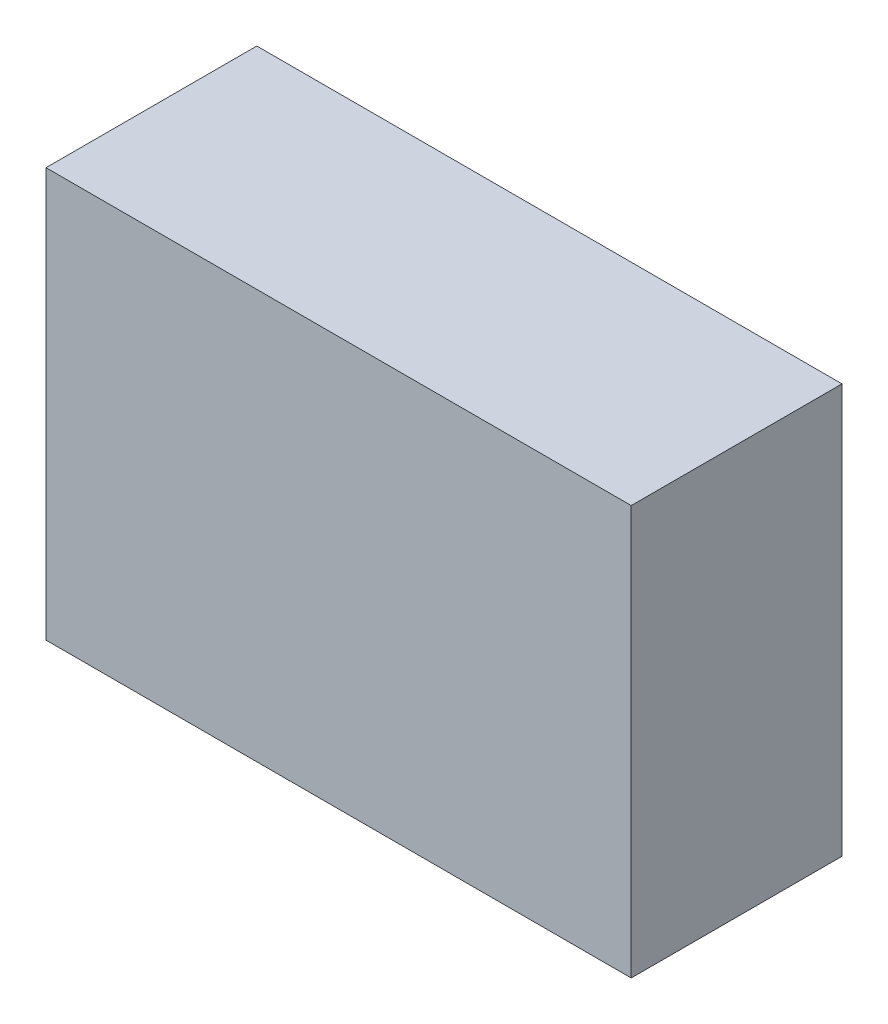
from build123d import *

# Parameters (mm, degrees)
SKETCH1_W           = 59.944
SKETCH1_H           = 41.91
BOSS_EXTRUDE1_DEPTH = 21.59


with BuildPart() as part:
    # Sketch1 → Boss-Extrude1 (new body)
    with BuildSketch(Plane.XY):
        with Locations((29.972, 20.955)):
            Rectangle(SKETCH1_W, SKETCH1_H)
    extrude(amount=BOSS_EXTRUDE1_DEPTH)


solid = part.part
